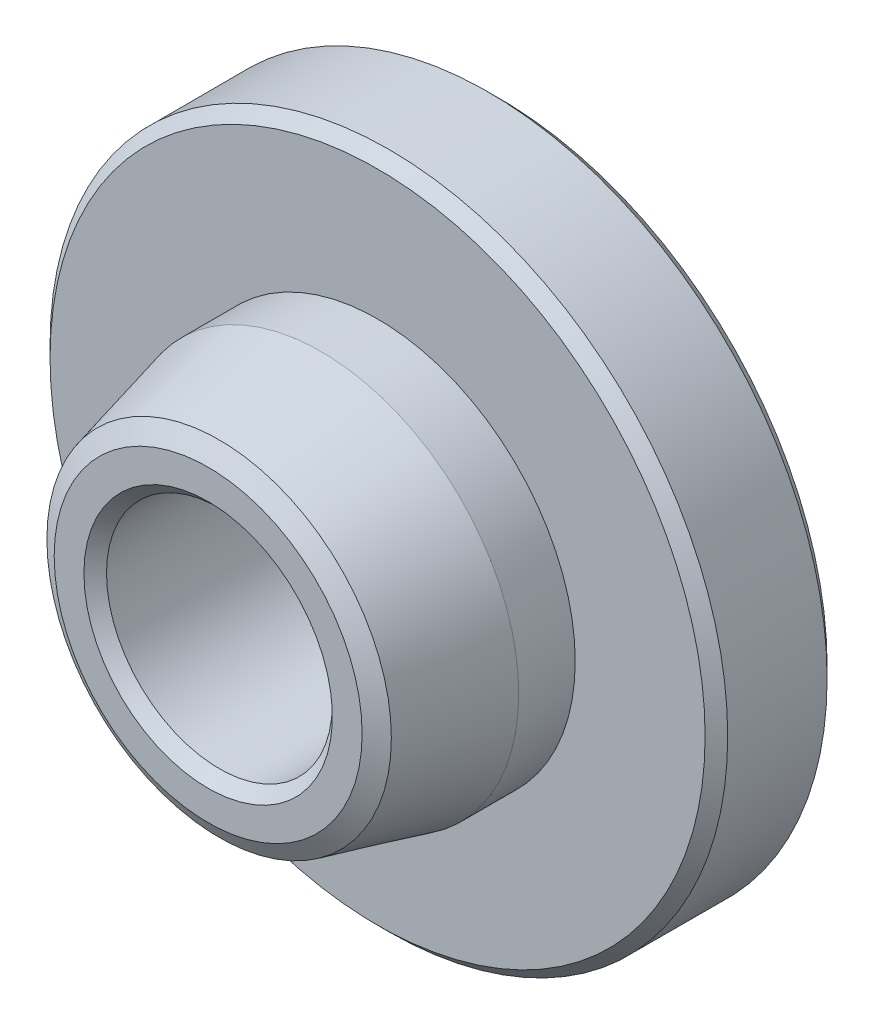
from build123d import *

# Parameters (mm, degrees)
AUFSATZ_LINEAR_AUSTRAGEN1_DEPTH = 1.3
VERRUNDUNG1_R                   = 0.5
KREISMUSTER1_COUNT              = 10
VERRUNDUNG1_OF_KREISMUSTER1_R   = 0.5
FASE1_SIZE2                     = 0.2
FASE1_SIZE                      = 0.274584275
FASE1_EDGE_2_SIZE               = 0.2
FASE1_EDGE_3_SIZE               = 0.2
FASE1_EDGE_4_SIZE               = 0.2
FASE1_EDGE_5_SIZE               = 0.2


with BuildPart() as part:
    # Skizze1 → Rotation1 (revolve)
    with BuildSketch(Plane(origin=(0, 0, 0), x_dir=(0, 0, -1), z_dir=(1, 0, 0))):
        Polygon((0, 2), (-4.66, 2), (-4.66, 3.001343994), (-2.66, 3.5), (-1.66, 3.5), (-1.66, 6), (0, 6), (1.3, 6), (1.3, 4.57), (0, 4.57), align=None)
    revolve(axis=Axis((0, 0, 23.408695652), (0, 0, -1)))

    # Skizze4 → Aufsatz-Linear austragen1 (add)
    with BuildSketch(Plane(origin=(0, 0, 0), x_dir=(-1, 0, 0), z_dir=(0, 0, -1))):
        with BuildLine():
            Line((-0.808470756, 3.57), (-1.2, 4.409637173))
            ThreePointArc((-1.2, 4.409637173), (0, 4.57), (1.2, 4.409637173))
            Line((1.2, 4.409637173), (0.808470756, 3.57))
            Line((0.808470756, 3.57), (-0.808470756, 3.57))
        make_face()
    aufsatz_linear_austragen1 = extrude(amount=AUFSATZ_LINEAR_AUSTRAGEN1_DEPTH)

    # Verrundung1
    verrundung1_edges = [part.edges().sort_by_distance(p)[0] for p in [
        (-0.808470756, 3.57, -0.65),
        (0.808470756, 3.57, -0.65),
    ]]
    fillet(verrundung1_edges, radius=VERRUNDUNG1_R)

    # Kreismuster1: Aufsatz-Linear austragen1 ×10 about axis
    kreismuster1_axis = Axis((0, 0, 0), (0, 0, 1))
    for i in range(1, KREISMUSTER1_COUNT):
        add(aufsatz_linear_austragen1.rotate(kreismuster1_axis, i * 360 / KREISMUSTER1_COUNT))

    # Verrundung1 of Kreismuster1
    verrundung1_of_kreismuster1_edges = [part.edges().sort_by_distance(p)[0] for p in [
        (-2.752459932, 2.412983483, -0.65),
        (-1.44432677, 3.363397857, -0.65),
        (-3.645102966, 0.334289289, -0.65),
        (-3.14544056, 1.872092051, -0.65),
        (-3.14544056, -1.872092051, -0.65),
        (-3.645102966, -0.334289289, -0.65),
        (-1.44432677, -3.363397857, -0.65),
        (-2.752459932, -2.412983483, -0.65),
        (0.808470756, -3.57, -0.65),
        (-0.808470756, -3.57, -0.65),
        (2.752459932, -2.412983483, -0.65),
        (1.44432677, -3.363397857, -0.65),
        (3.645102966, -0.334289289, -0.65),
        (3.14544056, -1.872092051, -0.65),
        (3.14544056, 1.872092051, -0.65),
        (3.645102966, 0.334289289, -0.65),
        (1.44432677, 3.363397857, -0.65),
        (2.752459932, 2.412983483, -0.65),
    ]]
    fillet(verrundung1_of_kreismuster1_edges, radius=VERRUNDUNG1_OF_KREISMUSTER1_R)

    # Skizze5 → Schnitt-Rotation1 (revolve, cut)
    with BuildSketch(Plane(origin=(0, 0, 0), x_dir=(0, 0, -1), z_dir=(1, 0, 0))):
        with BuildLine():
            Line((0.5, 6), (0.5, 5))
            Line((0.5, 5), (1.153553391, 4.346446609))
            ThreePointArc((1.153553391, 4.346446609), (1.261939766, 4.184234935), (1.3, 3.992893219))
            Line((1.3, 3.992893219), (1.3, 2.59724793))
            Line((1.3, 2.59724793), (2.535311957, 2.59724793))
            Line((2.535311957, 2.59724793), (2.535311957, 6))
            Line((2.535311957, 6), (0.5, 6))
        make_face()
    revolve(axis=Axis((0, 0, -4.981936438), (0, 0, 1)), mode=Mode.SUBTRACT)

    # Fase1
    fase1_edges = [part.edges().sort_by_distance(p)[0] for p in [
        (0, -3.001343994, 4.66),
    ]]
    chamfer(fase1_edges, length=FASE1_SIZE, length2=FASE1_SIZE2)

    # Fase1 edge 2
    fase1_edge_2_edges = [part.edges().sort_by_distance(p)[0] for p in [
        (0, -2, 4.66),
    ]]
    chamfer(fase1_edge_2_edges, length=FASE1_EDGE_2_SIZE)

    # Fase1 edge 3
    fase1_edge_3_edges = [part.edges().sort_by_distance(p)[0] for p in [
        (0, -2, 0),
    ]]
    chamfer(fase1_edge_3_edges, length=FASE1_EDGE_3_SIZE)

    # Fase1 edge 4
    fase1_edge_4_edges = [part.edges().sort_by_distance(p)[0] for p in [
        (0, -6, -0.5),
    ]]
    chamfer(fase1_edge_4_edges, length=FASE1_EDGE_4_SIZE)

    # Fase1 edge 5
    fase1_edge_5_edges = [part.edges().sort_by_distance(p)[0] for p in [
        (0, -6, 1.66),
    ]]
    chamfer(fase1_edge_5_edges, length=FASE1_EDGE_5_SIZE)


solid = part.part
